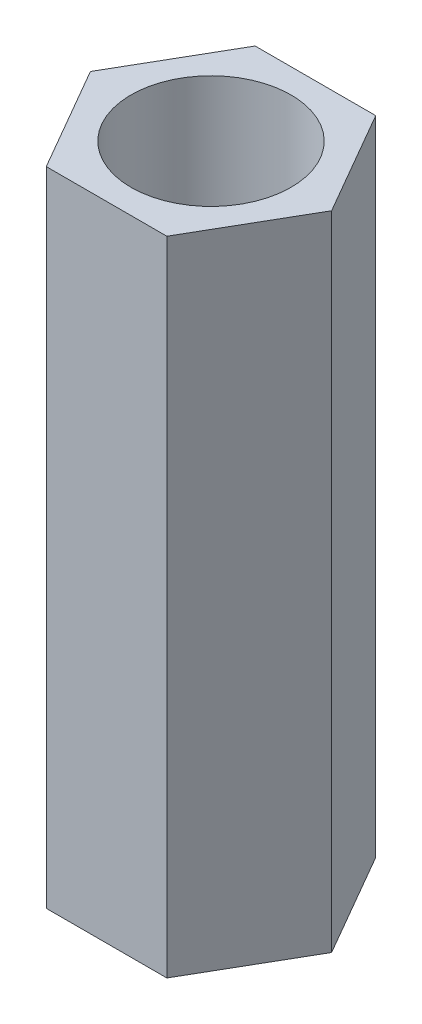
from build123d import *

# Parameters (mm, degrees)
SKETCH1_R           = 1.3
BOSS_EXTRUDE1_DEPTH = 10.43


with BuildPart() as part:
    # Sketch1 → Boss-Extrude1 (new body)
    with BuildSketch(Plane(origin=(0, 0, 0), x_dir=(1, 0, 0), z_dir=(0, 1, 0))):
        Polygon((0.979018569, -1.695709904), (1.958037139, 0), (0.979018569, 1.695709904), (-0.979018569, 1.695709904), (-1.958037139, 0), (-0.979018569, -1.695709904), align=None)
        Circle(SKETCH1_R, mode=Mode.SUBTRACT)
    extrude(amount=BOSS_EXTRUDE1_DEPTH)


solid = part.part
